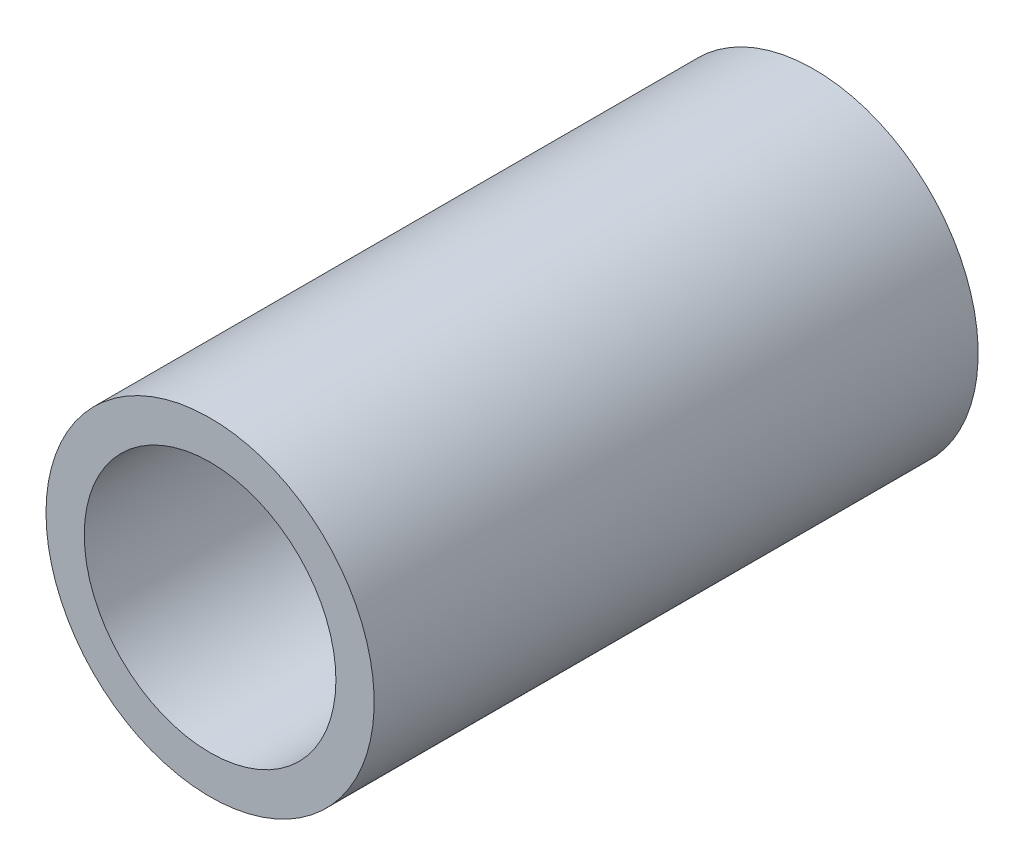
from build123d import *

# Parameters (mm, degrees)
SKETCH5_R           = 10.3505
SKETCH5_R_2         = 7.9375
BOSS_EXTRUDE1_DEPTH = 19.05


with BuildPart() as part:
    # Sketch5 → Boss-Extrude1 (new, symmetric)
    with BuildSketch(Plane.XY):
        with Locations(Location((0, 0, 0), (0, 0, 180))):
            Circle(SKETCH5_R)
        with Locations(Location((0, 0, 0), (0, 0, 180))):
            Circle(SKETCH5_R_2, mode=Mode.SUBTRACT)
    extrude(amount=BOSS_EXTRUDE1_DEPTH, both=True)


solid = part.part
